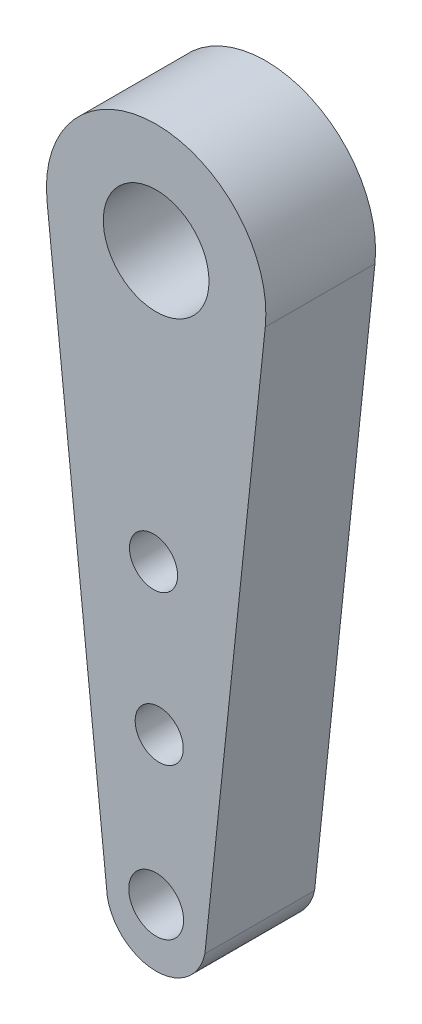
from build123d import *

# Parameters (mm, degrees)
SKETCH1_R           = 1.445304889
BOSS_EXTRUDE1_DEPTH = 3
SKETCH2_R           = 0.75
CUT_EXTRUDE1_DEPTH  = 10
SKETCH3_R           = 0.657732985
CUT_EXTRUDE2_DEPTH  = 4
SKETCH4_R           = 0.657732985
CUT_EXTRUDE3_DEPTH  = 4


with BuildPart() as part:
    # Sketch1 → Boss-Extrude1 (new body)
    with BuildSketch(Plane.XY):
        with BuildLine():
            Line((2.709665951, -9.119248637), (4.330233257, 6.26308765))
            ThreePointArc((4.330233257, 6.26308765), (3.57642555, 8.584523689), (1.346744655, 9.577405579))
            ThreePointArc((1.346744655, 9.577405579), (-0.88293624, 8.584523689), (-1.636743947, 6.26308765))
            Line((-1.636743947, 6.26308765), (-0.016176641, -9.119248637))
            Line((-0.016176641, -9.119248637), (0.013745769, -9.403270519))
            ThreePointArc((0.013745769, -9.403270519), (1.346744655, -10.482169933), (2.679743541, -9.403270519))
            Line((2.679743541, -9.403270519), (2.709665951, -9.119248637))
        make_face()
        with Locations((1.346744655, 6.577405579)):
            Circle(SKETCH1_R, mode=Mode.SUBTRACT)
    extrude(amount=BOSS_EXTRUDE1_DEPTH)

    # Sketch2 → Cut-Extrude1 (cut)
    with BuildSketch(Plane.XY.offset(3)):
        with Locations((1.346744655, -8.903103928)):
            Circle(SKETCH2_R)
    extrude(amount=-CUT_EXTRUDE1_DEPTH, mode=Mode.SUBTRACT)

    # Sketch3 → Cut-Extrude2 (cut, through all)
    with BuildSketch(Plane(origin=(0, 0, 0), x_dir=(-1, 0, 0), z_dir=(0, 0, -1))):
        with Locations((-1.275359723, -0.820045285)):
            Circle(SKETCH3_R)
    extrude(amount=-CUT_EXTRUDE2_DEPTH, mode=Mode.SUBTRACT)

    # Sketch4 → Cut-Extrude3 (cut, through all)
    with BuildSketch(Plane(origin=(0, 0, 0), x_dir=(-1, 0, 0), z_dir=(0, 0, -1))):
        with Locations((-1.43062658, -4.837170951)):
            Circle(SKETCH4_R)
    extrude(amount=-CUT_EXTRUDE3_DEPTH, mode=Mode.SUBTRACT)


solid = part.part
